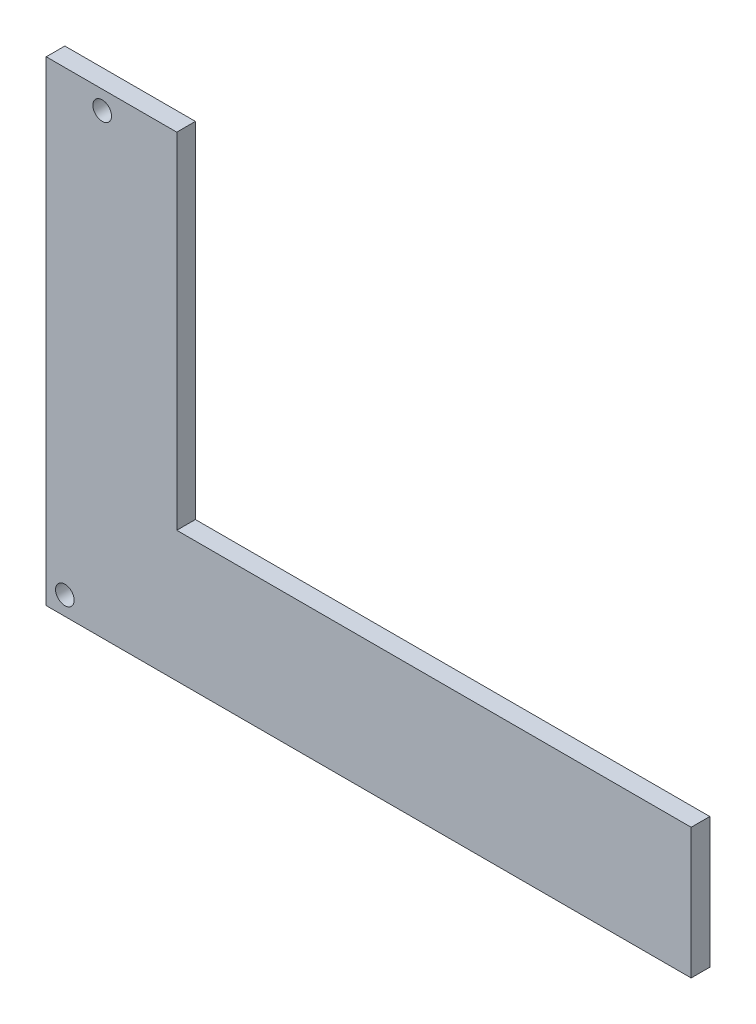
from build123d import *

# Parameters (mm, degrees)
BOSS_EXTRUDE1_DEPTH = 5
SKETCH3_R           = 2.5
CUT_EXTRUDE1_DEPTH  = 6


with BuildPart() as part:
    # Sketch2 → Boss-Extrude1 (new body)
    with BuildSketch(Plane.XY):
        Polygon((-18.000000008, 109.507702779), (17.018717612, 109.507702779), (17.018717612, 17.017935082), (155, 17.017935082), (155, -18), (-18.000000008, -18), align=None)
    extrude(amount=BOSS_EXTRUDE1_DEPTH)

    # Sketch3 → Cut-Extrude1 (cut, through all)
    with BuildSketch(Plane.XY.offset(5)):
        with Locations((-13.000000008, -13)):
            Circle(SKETCH3_R)
        with Locations((-2.981282388, 104.507702779)):
            Circle(SKETCH3_R)
    extrude(amount=-CUT_EXTRUDE1_DEPTH, mode=Mode.SUBTRACT)


solid = part.part
